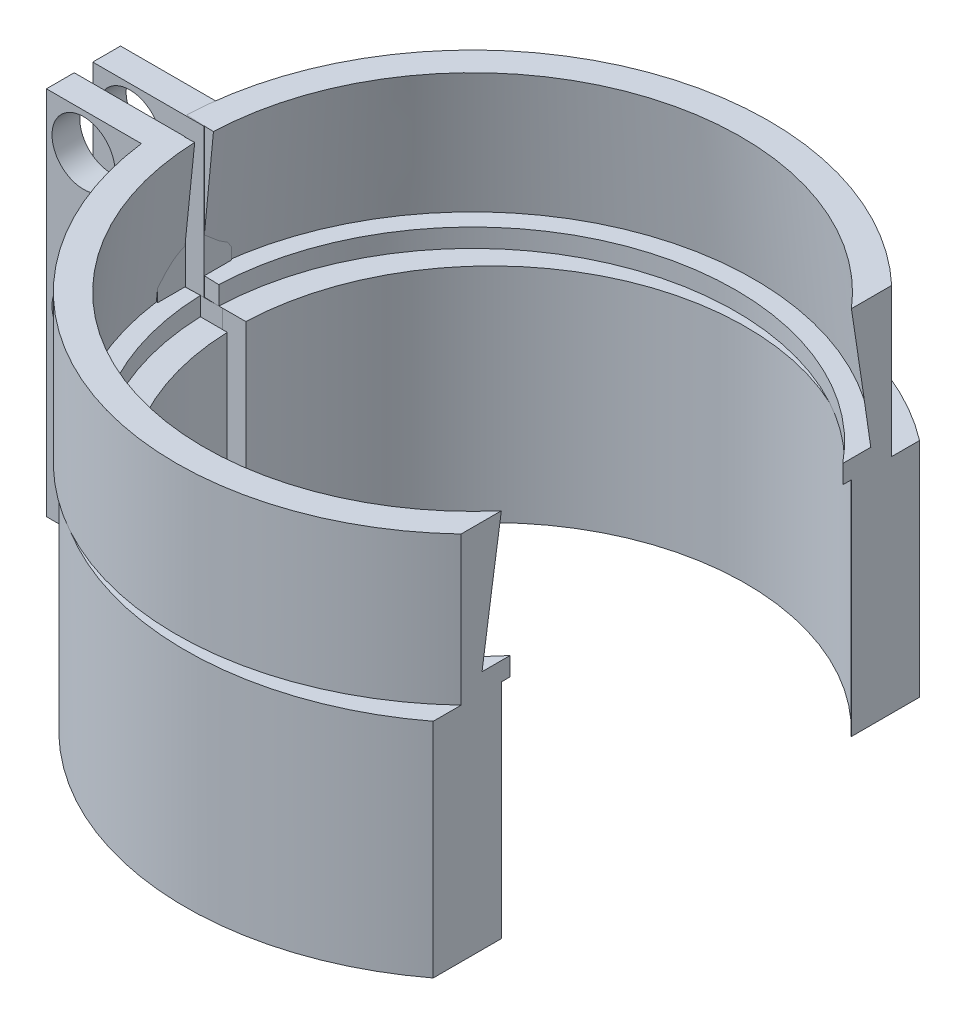
from build123d import *
from build123d.topology import SkipClean

# Parameters (mm, degrees)
BOSS_EXTRUDE1_DEPTH      = 12
REVOLVE1_ANGLE           = 268
REVOLVE1_OTHER_WAY_ANGLE = 88
CUT_EXTRUDE1_DEPTH       = 36.01785259
CUT_EXTRUDE1_DEPTH_BACK  = 36.01785259
SKETCH4_R                = 1.7
SKETCH5_W                = 6
SKETCH5_H                = 8
SKETCH5_R                = 1.7
BOSS_EXTRUDE3_DEPTH      = 1.5
SKETCH6_W                = 6
SKETCH6_H                = 8
SKETCH6_R                = 1.7
BOSS_EXTRUDE6_DEPTH      = 1.5
SKETCH7_W                = 10.400805134
SKETCH7_H                = 29.241648581
CUT_EXTRUDE2_DEPTH       = 35.003676272


with BuildPart() as part:
    # Sketch1 → Boss-Extrude1 (new body)
    with BuildSketch(Plane(origin=(0, 0, 0), x_dir=(1, 0, 0), z_dir=(0, 1, 0))):
        with BuildLine():
            Line((-13.740839561, 0.501824818), (-14.997715427, 0.5))
            Line((-14.997715427, 0.5), (-22, 0.5))
            Line((-22, 0.5), (-22, 2))
            Line((-22, 2), (-16.378339354, 2))
            ThreePointArc((-16.378339354, 2), (-13.76213031, 9.10240459), (-8.25, 14.289419162))
            ThreePointArc((-8.25, 14.289419162), (16.5, 0), (-8.25, -14.289419162))
            ThreePointArc((-8.25, -14.289419162), (-13.76213031, -9.10240459), (-16.378339354, -2))
            Line((-16.378339354, -2), (-22, -2))
            Line((-22, -2), (-22, -0.5))
            Line((-22, -0.5), (-14.997715427, -0.5))
            Line((-14.997715427, -0.5), (-13.740839561, -0.501824818))
            ThreePointArc((-13.740839561, -0.501824818), (-11.780388739, -7.09118757), (-6.875, -11.907849302))
            ThreePointArc((-6.875, -11.907849302), (13.75, 0), (-6.875, 11.907849302))
            ThreePointArc((-6.875, 11.907849302), (-11.780388739, 7.09118757), (-13.740839561, 0.501824818))
        make_face()
    extrude(amount=BOSS_EXTRUDE1_DEPTH)

    # Sketch3 → Revolve1 (revolve)
    with BuildSketch(Plane(origin=(-1, 0, 0), x_dir=(0, 0, -1), z_dir=(1, 0, 0))):
        Polygon((-16, 12), (-16, 20), (-14.5, 20), (-15.2, 13), (-14.2, 13), (-14.2, 12), (-15, 12), align=None)
    revolve(axis=Axis((-1, 12, 0), (0, 1, 0)), revolution_arc=REVOLVE1_ANGLE)

    # Sketch3 → Revolve1 other way (revolve)
    with SkipClean():  # the faces are left unmerged after this step: merging them gives an invalid solid
        with BuildSketch(Plane(origin=(-1, 0, 0), x_dir=(0, 0, -1), z_dir=(1, 0, 0))):
            Polygon((-16, 12), (-16, 20), (-14.5, 20), (-15.2, 13), (-14.2, 13), (-14.2, 12), (-15, 12), align=None)
        revolve(axis=Axis((-1, 12, 0), (0, -1, 0)), revolution_arc=REVOLVE1_OTHER_WAY_ANGLE)

    # Sketch4 → Cut-Extrude1 (cut, two sides: drawn at the far end of the back side and taken through both)
    with SkipClean():  # the faces are left unmerged after this step: merging them gives an invalid solid
        with BuildSketch(Plane(origin=(0, 0, -2), x_dir=(-1, 0, 0), z_dir=(0, 0, -1)).offset(-CUT_EXTRUDE1_DEPTH_BACK)):
            with Locations((20, 10)):
                Circle(SKETCH4_R)
            with Locations((18.455192267, 2.5)):
                Circle(SKETCH4_R)
        extrude(amount=CUT_EXTRUDE1_DEPTH + CUT_EXTRUDE1_DEPTH_BACK, mode=Mode.SUBTRACT)

    # Sketch5 → Boss-Extrude3 (add)
    with BuildSketch(Plane.XY.offset(2)):
        with Locations((-19, 16)):
            Rectangle(SKETCH5_W, SKETCH5_H)
        with Locations((-20, 18)):
            Circle(SKETCH5_R, mode=Mode.SUBTRACT)
    extrude(amount=-BOSS_EXTRUDE3_DEPTH)

    # Sketch7 → Cut-Extrude2 (cut, through all)
    with BuildSketch(Plane.XZ):
        with Locations((15.2003418, 0.918688158)):
            Rectangle(SKETCH7_W, SKETCH7_H)
    extrude(amount=-CUT_EXTRUDE2_DEPTH, mode=Mode.SUBTRACT)


with BuildPart() as body_2:
    # Sketch6 → Boss-Extrude6 (new body)
    with BuildSketch(Plane(origin=(0, 0, -2), x_dir=(-1, 0, 0), z_dir=(0, 0, -1))):
        with Locations((19, 16)):
            Rectangle(SKETCH6_W, SKETCH6_H)
        with Locations((20, 18)):
            Circle(SKETCH6_R, mode=Mode.SUBTRACT)
    extrude(amount=-BOSS_EXTRUDE6_DEPTH)


with BuildPart() as cut_extrude2_piece_1:
    # of the separate pieces the step leaves, piece 1, a body of its own (cut_extrude2_pieces)
    add(part.part.solids().sort_by_distance((-16.378339354, 0, 2))[0])


with BuildPart() as cut_extrude2_piece_2:
    # of the separate pieces the step leaves, piece 2, a body of its own (cut_extrude2_pieces)
    add(part.part.solids().sort_by_distance((-16.990253232, 20, -0.558391947))[0])


solid = Compound([body_2.part, cut_extrude2_piece_1.part, cut_extrude2_piece_2.part])
